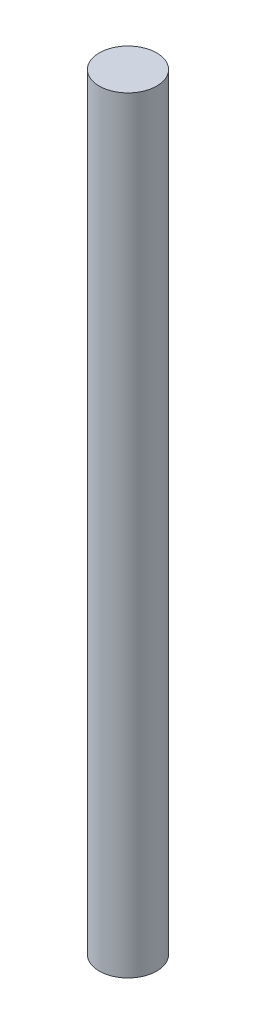
from build123d import *

# Parameters (mm, degrees)
SKETCH1_R           = 4.7625
BOSS_EXTRUDE1_DEPTH = 127


with BuildPart() as part:
    # Sketch1 → Boss-Extrude1 (new body)
    with BuildSketch(Plane(origin=(0, 0, 0), x_dir=(1, 0, 0), z_dir=(0, 1, 0))):
        Circle(SKETCH1_R)
    extrude(amount=BOSS_EXTRUDE1_DEPTH)


solid = part.part
